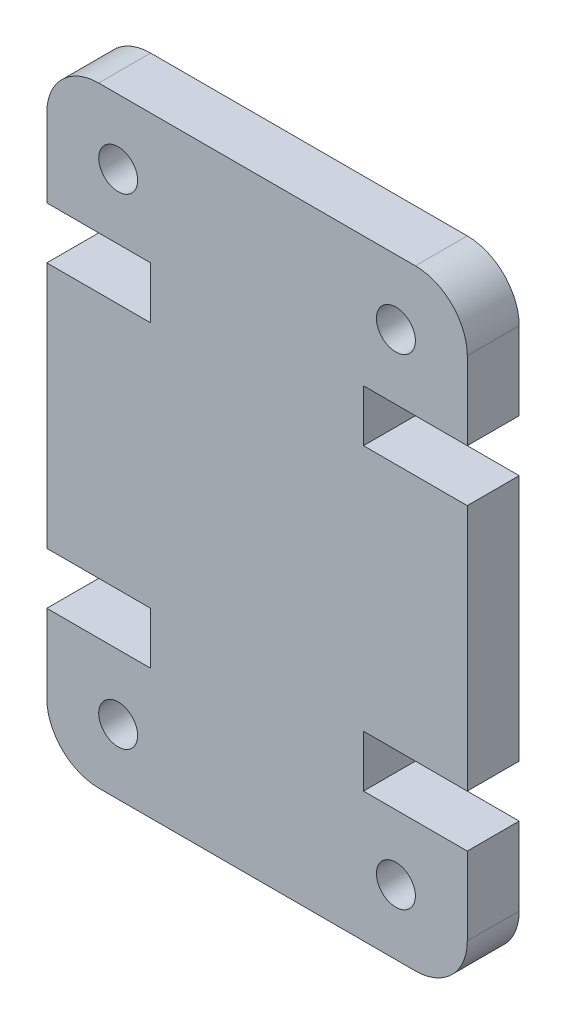
from build123d import *

# Parameters (mm, degrees)
SKETCH1_R           = 0.75
BOSS_EXTRUDE1_DEPTH = 2


with BuildPart() as part:
    # Sketch1 → Boss-Extrude1 (new body)
    with BuildSketch(Plane.XY):
        with BuildLine():
            Line((16.2, 5), (16.2, 2))
            ThreePointArc((16.2, 2), (15.614213562, 0.585786438), (14.2, 0))
            Line((14.2, 0), (2, 0))
            ThreePointArc((2, 0), (0.585786438, 0.585786438), (0, 2))
            Line((0, 2), (0, 5))
            Line((0, 5), (4, 5))
            Line((4, 5), (4, 7))
            Line((4, 7), (0, 7))
            Line((0, 7), (0, 16.525))
            Line((0, 16.525), (4, 16.525))
            Line((4, 16.525), (4, 18.525))
            Line((4, 18.525), (0, 18.525))
            Line((0, 18.525), (0, 21.525))
            ThreePointArc((0, 21.525), (0.585786438, 22.939213562), (2, 23.525))
            Line((2, 23.525), (14.2, 23.525))
            ThreePointArc((14.2, 23.525), (15.614213562, 22.939213562), (16.2, 21.525))
            Line((16.2, 21.525), (16.2, 18.525))
            Line((16.2, 18.525), (12.2, 18.525))
            Line((12.2, 18.525), (12.2, 16.525))
            Line((12.2, 16.525), (16.2, 16.525))
            Line((16.2, 16.525), (16.2, 7))
            Line((16.2, 7), (12.2, 7))
            Line((12.2, 7), (12.2, 5))
            Line((12.2, 5), (16.2, 5))
        make_face()
        with Locations((13.45, 2.5)):
            Circle(SKETCH1_R, mode=Mode.SUBTRACT)
        with Locations((2.75, 21.025)):
            Circle(SKETCH1_R, mode=Mode.SUBTRACT)
        with Locations((13.45, 21.025)):
            Circle(SKETCH1_R, mode=Mode.SUBTRACT)
        with Locations((2.75, 2.5)):
            Circle(SKETCH1_R, mode=Mode.SUBTRACT)
    extrude(amount=BOSS_EXTRUDE1_DEPTH)


solid = part.part
